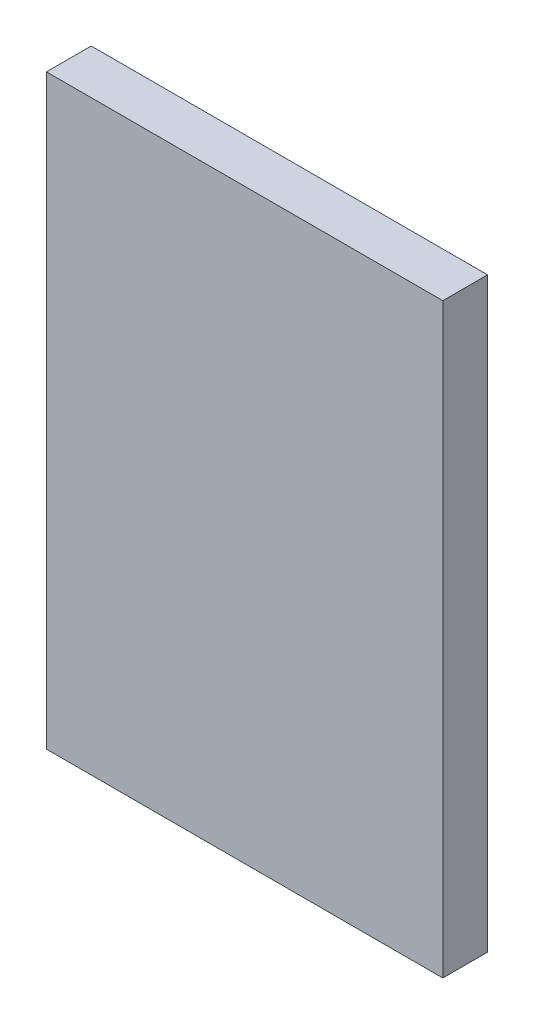
from build123d import *

# Parameters (mm, degrees)
CROQUIS1_W              = 450
CROQUIS1_H              = 666
SALIENTE_EXTRUIR1_DEPTH = 50.8


with BuildPart() as part:
    # Croquis1 → Saliente-Extruir1 (new body)
    with BuildSketch(Plane.XY):
        Rectangle(CROQUIS1_W, CROQUIS1_H)
    extrude(amount=SALIENTE_EXTRUIR1_DEPTH)


solid = part.part
